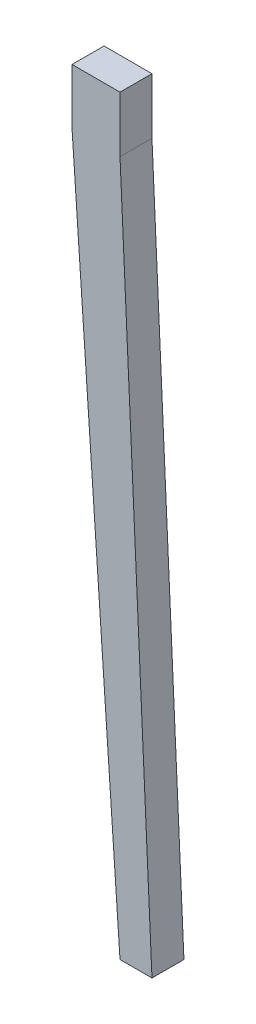
from build123d import *

# Parameters (mm, degrees)
SKETCH1_W           = 38.1
SKETCH1_H           = 44.45
BOSS_EXTRUDE1_DEPTH = 25.4


with BuildPart() as part:
    # Sketch1 → Boss-Extrude1 (new body)
    with BuildSketch(Plane.XY):
        with Locations((19.05, -22.225)):
            Rectangle(SKETCH1_W, SKETCH1_H)
        Polygon((38.1, -596.9), (0, -44.45), (38.1, -44.45), (63.5, -596.9), align=None)
    extrude(amount=BOSS_EXTRUDE1_DEPTH)


solid = part.part
